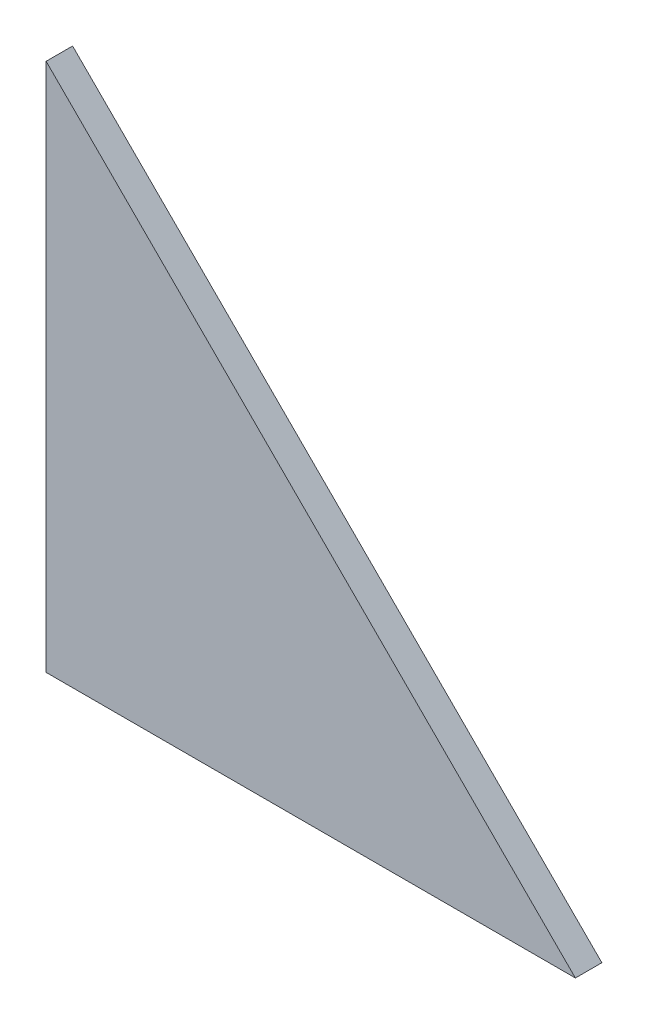
from build123d import *

# Parameters (mm, degrees)
BOSS_EXTRUDE1_DEPTH = 5


with BuildPart() as part:
    # Sketch1 → Boss-Extrude1 (new body)
    with BuildSketch(Plane.XY):
        Polygon((0, 100), (100, 0), (0, 0), align=None)
    extrude(amount=BOSS_EXTRUDE1_DEPTH)


solid = part.part
